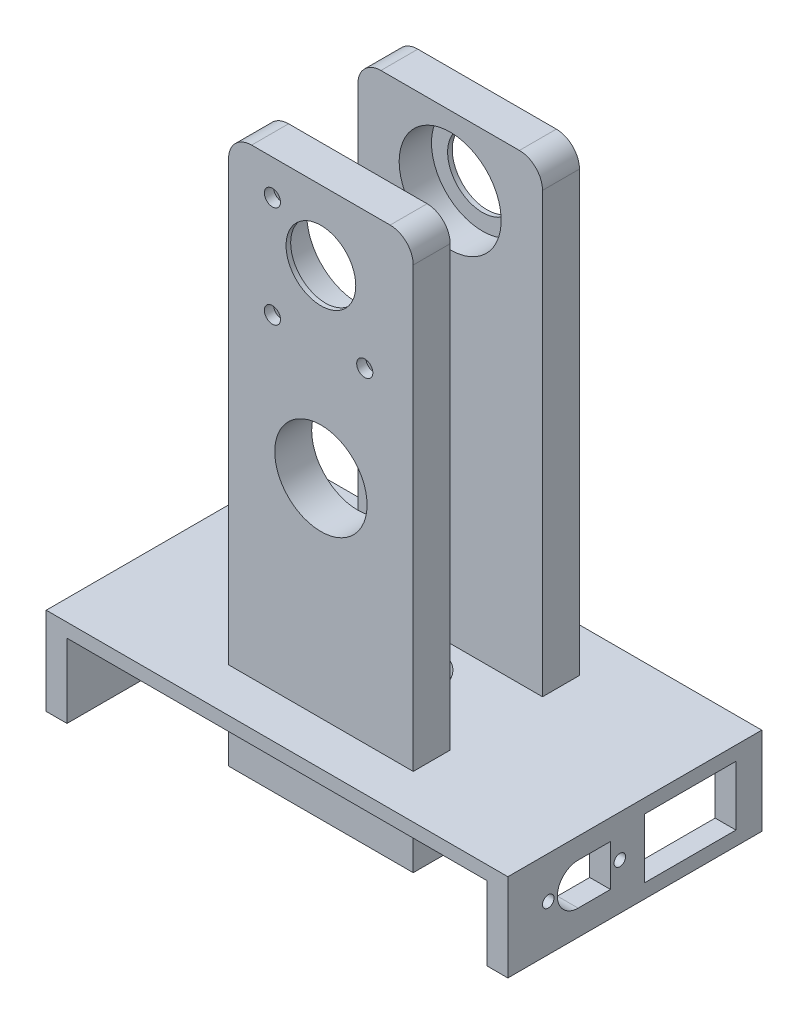
from build123d import *

# Parameters (mm, degrees)
SKETCH1_W            = 100
SKETCH1_H            = 55
BOSS_EXTRUDE1_DEPTH  = 19
SKETCH2_W            = 91
SKETCH2_H            = 91
CUT_EXTRUDE1_DEPTH   = 16
CUT_EXTRUDE3_REACH   = 102
SKETCH3_R            = 1.25
CUT_EXTRUDE13_REACH  = 102
SKETCH15_W           = 19.8
SKETCH15_H           = 12.9
BOSS_EXTRUDE2_START  = -19
SKETCH6_W            = 40
SKETCH6_H            = 8
BOSS_EXTRUDE2_DEPTH  = 119
SKETCH7_R            = 11.05
CUT_EXTRUDE5_DEPTH   = 7
SKETCH8_R            = 7.55
CUT_EXTRUDE6_DEPTH   = 1
FILLET1_R            = 5
FILLET1_OF_MIRROR2_R = 5
CUT_EXTRUDE7_REACH   = 21
SKETCH9_R            = 7.5
CUT_EXTRUDE10_REACH  = 47.5
SKETCH12_R           = 10
CUT_EXTRUDE11_REACH  = 47.5
SKETCH13_R           = 1.75
CUT_EXTRUDE12_DEPTH  = 6


with BuildPart() as part:
    # Sketch1 → Boss-Extrude1 (new body)
    with BuildSketch(Plane(origin=(0, 0, 0), x_dir=(1, 0, 0), z_dir=(0, 1, 0))):
        Rectangle(SKETCH1_W, SKETCH1_H)
    extrude(amount=BOSS_EXTRUDE1_DEPTH)

    # Sketch2 → Cut-Extrude1 (cut)
    with BuildSketch(Plane.XZ):
        Rectangle(SKETCH2_W, SKETCH2_H)
    extrude(amount=-CUT_EXTRUDE1_DEPTH, mode=Mode.SUBTRACT)

    # Sketch3 → Cut-Extrude3 (cut, up to next)
    with BuildSketch(Plane(origin=(50, 0, 0), x_dir=(0, 0, -1), z_dir=(1, 0, 0)), mode=Mode.PRIVATE) as cut_extrude3_sk1:
        with Locations((-18.75, 10)):
            Circle(SKETCH3_R)
    cut_extrude3_tool1 = extrude(cut_extrude3_sk1.sketch, amount=-CUT_EXTRUDE3_REACH, mode=Mode.PRIVATE) & part.part
    add(cut_extrude3_tool1.solids().sort_by_distance((50, 10, 18.75))[0], mode=Mode.SUBTRACT)
    # Sketch3 → Cut-Extrude3 (cut, up to next)
    with BuildSketch(Plane(origin=(50, 0, 0), x_dir=(0, 0, -1), z_dir=(1, 0, 0)), mode=Mode.PRIVATE) as cut_extrude3_sk2:
        with Locations((-3.25, 10)):
            Circle(SKETCH3_R)
    cut_extrude3_tool2 = extrude(cut_extrude3_sk2.sketch, amount=-CUT_EXTRUDE3_REACH, mode=Mode.PRIVATE) & part.part
    add(cut_extrude3_tool2.solids().sort_by_distance((50, 10, 3.25))[0], mode=Mode.SUBTRACT)
    # Sketch3 → Cut-Extrude3 (cut, up to next)
    with BuildSketch(Plane(origin=(50, 0, 0), x_dir=(0, 0, -1), z_dir=(1, 0, 0)), mode=Mode.PRIVATE) as cut_extrude3_sk3:
        with BuildLine():
            Line((-5.272727273, 5.5), (-5.272727273, 14.5))
            Line((-5.272727273, 14.5), (-12.278409091, 14.5))
            ThreePointArc((-12.278409091, 14.5), (-16.778409091, 10), (-12.278409091, 5.5))
            Line((-12.278409091, 5.5), (-5.272727273, 5.5))
        make_face()
    cut_extrude3_tool3 = extrude(cut_extrude3_sk3.sketch, amount=-CUT_EXTRUDE3_REACH, mode=Mode.PRIVATE) & part.part
    add(cut_extrude3_tool3.solids().sort_by_distance((50, 10, 10.590569))[0], mode=Mode.SUBTRACT)

    # Sketch15 → Cut-Extrude13 (cut, up to next)
    with BuildSketch(Plane(origin=(50, 0, 0), x_dir=(0, 0, -1), z_dir=(1, 0, 0)), mode=Mode.PRIVATE) as cut_extrude13_sk1:
        with Locations((12, 9.5)):
            Rectangle(SKETCH15_W, SKETCH15_H)
    cut_extrude13_tool1 = extrude(cut_extrude13_sk1.sketch, amount=-CUT_EXTRUDE13_REACH, mode=Mode.PRIVATE) & part.part
    add(cut_extrude13_tool1.solids().sort_by_distance((50, 9.5, -12))[0], mode=Mode.SUBTRACT)

    # Sketch6 → Boss-Extrude2 (add)
    with BuildSketch(Plane(origin=(0, 19, 0), x_dir=(1, 0, 0), z_dir=(0, 1, 0)).offset(BOSS_EXTRUDE2_START)):
        with Locations((0, -14)):
            Rectangle(SKETCH6_W, SKETCH6_H)
    boss_extrude2 = extrude(amount=BOSS_EXTRUDE2_DEPTH)

    # Sketch7 → Cut-Extrude5 (cut)
    with BuildSketch(Plane(origin=(0, 0, 10), x_dir=(-1, 0, 0), z_dir=(0, 0, -1))):
        with Locations((0, 103.9)):
            Circle(SKETCH7_R)
    cut_extrude5 = extrude(amount=-CUT_EXTRUDE5_DEPTH, mode=Mode.SUBTRACT)

    # Sketch8 → Cut-Extrude6 (cut)
    with BuildSketch(Plane.XY.offset(18)):
        with Locations((0, 103.9)):
            Circle(SKETCH8_R)
    cut_extrude6 = extrude(amount=-CUT_EXTRUDE6_DEPTH, mode=Mode.SUBTRACT)

    # Fillet1
    fillet1_edges = [part.edges().sort_by_distance(p)[0] for p in [
        (-20, 119, 14),
        (20, 119, 14),
    ]]
    fillet(fillet1_edges, radius=FILLET1_R)

    # Mirror2: Boss-Extrude2, Cut-Extrude5, Cut-Extrude6 across plane
    add(boss_extrude2.mirror(Plane.XY))
    add(cut_extrude5.mirror(Plane.XY), mode=Mode.SUBTRACT)
    add(cut_extrude6.mirror(Plane.XY), mode=Mode.SUBTRACT)

    # Fillet1 of Mirror2
    fillet1_of_mirror2_edges = [part.edges().sort_by_distance(p)[0] for p in [
        (-20, 119, -14),
        (20, 119, -14),
    ]]
    fillet(fillet1_of_mirror2_edges, radius=FILLET1_OF_MIRROR2_R)

    # Sketch9 → Cut-Extrude7 (cut, up to next)
    with BuildSketch(Plane(origin=(0, 19, 0), x_dir=(1, 0, 0), z_dir=(0, 1, 0)), mode=Mode.PRIVATE) as cut_extrude7_sk1:
        Circle(SKETCH9_R)
    cut_extrude7_tool1 = extrude(cut_extrude7_sk1.sketch, amount=-CUT_EXTRUDE7_REACH, mode=Mode.PRIVATE) & part.part
    add(cut_extrude7_tool1.solids().sort_by_distance((0, 19, 0))[0], mode=Mode.SUBTRACT)

    # Sketch12 → Cut-Extrude10 (cut, up to next)
    with BuildSketch(Plane.XY.offset(18), mode=Mode.PRIVATE) as cut_extrude10_sk1:
        with Locations((0, 64)):
            Circle(SKETCH12_R)
    cut_extrude10_tool1 = extrude(cut_extrude10_sk1.sketch, amount=-CUT_EXTRUDE10_REACH, mode=Mode.PRIVATE) & part.part
    add(cut_extrude10_tool1.solids().sort_by_distance((0, 64, 18))[0], mode=Mode.SUBTRACT)

    # Sketch13 → Cut-Extrude11 (cut, up to next)
    with BuildSketch(Plane.XY.offset(18), mode=Mode.PRIVATE) as cut_extrude11_sk1:
        with Locations((-10.5, 89.4)):
            Circle(SKETCH13_R)
    cut_extrude11_tool1 = extrude(cut_extrude11_sk1.sketch, amount=-CUT_EXTRUDE11_REACH, mode=Mode.PRIVATE) & part.part
    add(cut_extrude11_tool1.solids().sort_by_distance((-10.5, 89.4, 18))[0], mode=Mode.SUBTRACT)
    # Sketch13 → Cut-Extrude11 (cut, up to next)
    with BuildSketch(Plane.XY.offset(18), mode=Mode.PRIVATE) as cut_extrude11_sk2:
        with Locations((-10.5, 111.4)):
            Circle(SKETCH13_R)
    cut_extrude11_tool2 = extrude(cut_extrude11_sk2.sketch, amount=-CUT_EXTRUDE11_REACH, mode=Mode.PRIVATE) & part.part
    add(cut_extrude11_tool2.solids().sort_by_distance((-10.5, 111.4, 18))[0], mode=Mode.SUBTRACT)
    # Sketch13 → Cut-Extrude11 (cut, up to next)
    with BuildSketch(Plane.XY.offset(18), mode=Mode.PRIVATE) as cut_extrude11_sk3:
        with Locations((9.5, 89.4)):
            Circle(SKETCH13_R)
    cut_extrude11_tool3 = extrude(cut_extrude11_sk3.sketch, amount=-CUT_EXTRUDE11_REACH, mode=Mode.PRIVATE) & part.part
    add(cut_extrude11_tool3.solids().sort_by_distance((9.5, 89.4, 18))[0], mode=Mode.SUBTRACT)

    # Sketch14 → Cut-Extrude12 (cut)
    with BuildSketch(Plane(origin=(0, 0, 10), x_dir=(-1, 0, 0), z_dir=(0, 0, -1))):
        Polygon((-11.174315781, 92.3), (-7.825684219, 92.3), (-6.151368439, 89.4), (-7.825684219, 86.5), (-11.174315781, 86.5), (-12.848631561, 89.4), align=None)
        Polygon((13.848631561, 89.4), (12.174315781, 92.3), (8.825684219, 92.3), (7.151368439, 89.4), (8.825684219, 86.5), (12.174315781, 86.5), align=None)
        Polygon((7.151368439, 111.4), (8.825684219, 114.3), (12.174315781, 114.3), (13.848631561, 111.4), (12.174315781, 108.5), (8.825684219, 108.5), align=None)
    extrude(amount=-CUT_EXTRUDE12_DEPTH, mode=Mode.SUBTRACT)


solid = part.part
